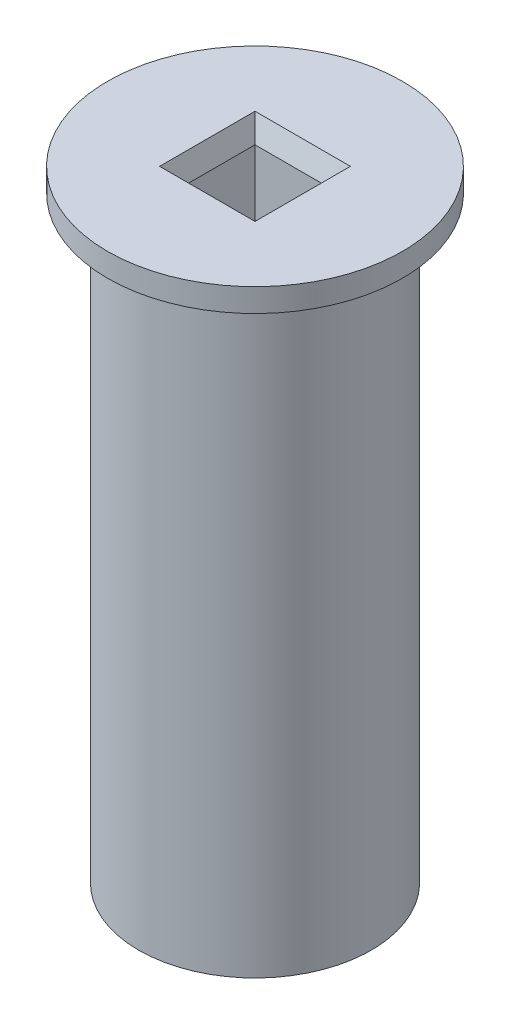
from build123d import *

# Parameters (mm, degrees)
SKETCH_1_R          = 15
SKETCH_1_W          = 10.3
SKETCH_1_H          = 10.3
EXTRUDE_1_DEPTH     = 80
SKETCH1_R           = 19
SKETCH1_W           = 10.3
SKETCH1_H           = 10.3
BOSS_EXTRUDE1_DEPTH = 3
CHAMFER1_SIZE       = 1
CHAMFER1_SIZE2      = 2.747477419


with BuildPart() as part:
    # Эскиз1 → Бобышка-Вытянуть1 (new body)
    with BuildSketch(Plane(origin=(0, 0, 0), x_dir=(1, 0, 0), z_dir=(0, 1, 0))):
        Circle(SKETCH_1_R)
        Rectangle(SKETCH_1_W, SKETCH_1_H, mode=Mode.SUBTRACT)
    extrude(amount=EXTRUDE_1_DEPTH)

    # Sketch1 → Boss-Extrude1 (add)
    with BuildSketch(Plane(origin=(0, 80, 0), x_dir=(1, 0, 0), z_dir=(0, 1, 0))):
        Circle(SKETCH1_R)
        Rectangle(SKETCH1_W, SKETCH1_H, mode=Mode.SUBTRACT)
    extrude(amount=-BOSS_EXTRUDE1_DEPTH)

    # Chamfer1
    chamfer1_edges = [part.edges().sort_by_distance(p)[0] for p in [
        (0, 80, -5.15),
        (-5.15, 80, 0),
        (0, 80, 5.15),
        (5.15, 80, 0),
    ]]
    chamfer1_side = [part.faces().sort_by_distance(p)[0] for p in [
        (-18.462598846, 80, 0),
    ]]
    chamfer(chamfer1_edges, length=CHAMFER1_SIZE, length2=CHAMFER1_SIZE2, reference=chamfer1_side[0])


solid = part.part
